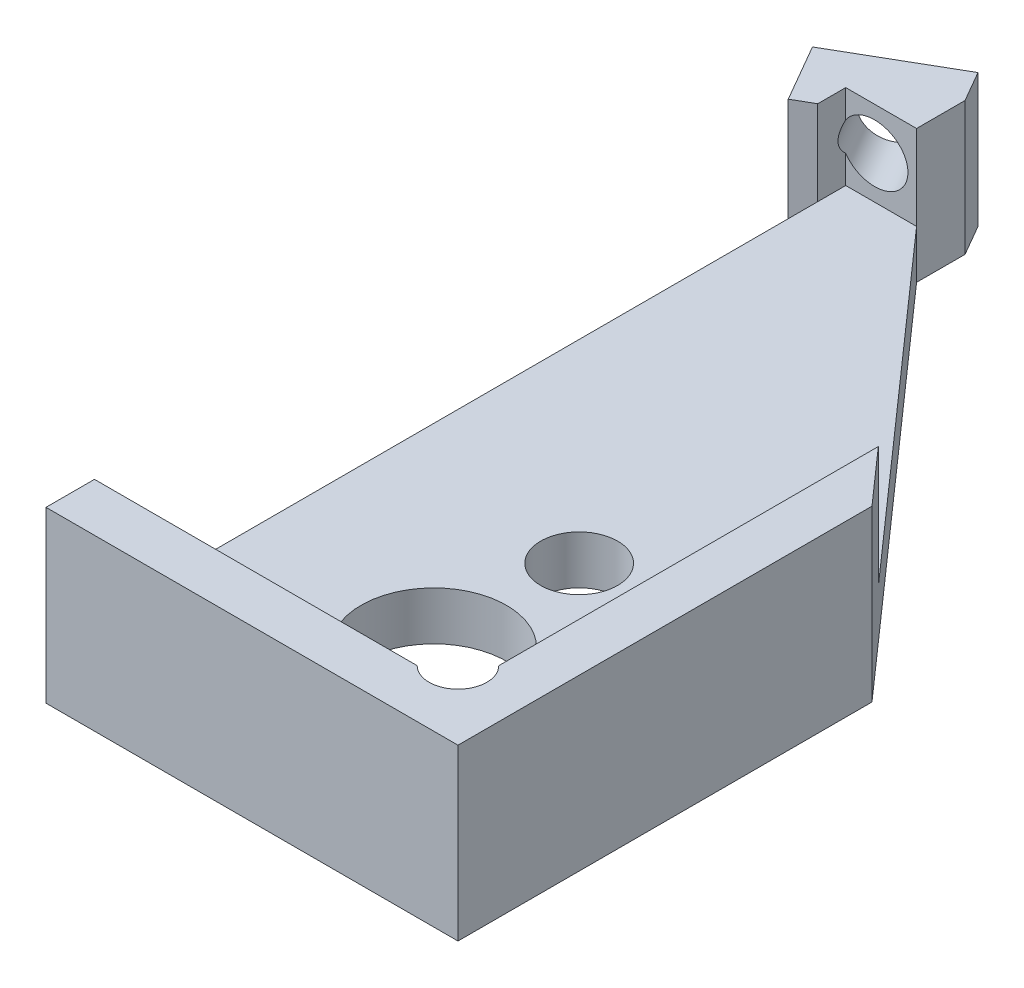
from build123d import *

# Parameters (mm, degrees)
SKETCH1_W                     = 8.5
SKETCH1_H                     = 17.5
BOSS_EXTRUDE1_DEPTH           = 3.5
SKETCH2_W                     = 6.5
SKETCH2_H                     = 15.5
CUT_EXTRUDE1_DEPTH            = 2.5
SKETCH3_R                     = 1.5
GRIN_HOLE_DEPTH               = 2
SKETCH6_R                     = 0.5953125
CORNER_DIVOT_DEPTH            = 2.5
SKETCH7_R                     = 0.79375
MAGNET_HOLES_DEPTH            = 2
BOSS_EXTRUDE2_DEPTH           = 3.5
SKETCH14_W                    = 5.965258944
SKETCH14_H                    = 5.132960456
SET_SCREW_EXTENSION_DEPTH     = 0.75
TAP_DRILL_FOR_0_80_TAP1_D     = 1.19126
TAP_DRILL_FOR_0_80_TAP1_DEPTH = 7.11
TAP_DRILL_FOR_0_80_TAP1_TIP   = 0.357890611
DIAGONAL_CUT_DEPTH            = 5
SKETCH16_W                    = 1
SKETCH16_H                    = 15.5
VERTICAL_CUT_DEPTH            = 3


with BuildPart() as part:
    # Sketch1 → Boss-Extrude1 (new body)
    with BuildSketch(Plane(origin=(0, 0, 0), x_dir=(1, 0, 0), z_dir=(0, 1, 0))):
        Rectangle(SKETCH1_W, SKETCH1_H)
    extrude(amount=BOSS_EXTRUDE1_DEPTH)

    # Sketch2 → Cut-Extrude1 (cut)
    with BuildSketch(Plane(origin=(0, 3.5, 0), x_dir=(1, 0, 0), z_dir=(0, 1, 0))):
        Rectangle(SKETCH2_W, SKETCH2_H)
    extrude(amount=-CUT_EXTRUDE1_DEPTH, mode=Mode.SUBTRACT)

    # Sketch3 → GRIN Hole (cut, through all)
    with BuildSketch(Plane(origin=(0, 1, 0), x_dir=(1, 0, 0), z_dir=(0, 1, 0))):
        with Locations((-0.25, -4.75)):
            Circle(SKETCH3_R)
    extrude(amount=-GRIN_HOLE_DEPTH, mode=Mode.SUBTRACT)

    # Sketch6 → Corner divot (cut)
    with BuildSketch(Plane(origin=(0, 3.5, 0), x_dir=(1, 0, 0), z_dir=(0, 1, 0))):
        with Locations((2.829050494, -7.329050494)):
            Circle(SKETCH6_R)
    extrude(amount=-CORNER_DIVOT_DEPTH, mode=Mode.SUBTRACT)

    # Sketch7 → Magnet Holes (cut, through all)
    with BuildSketch(Plane(origin=(0, 1, 0), x_dir=(1, 0, 0), z_dir=(0, 1, 0))):
        with Locations((-0.25, -1.75)):
            Circle(SKETCH7_R)
        with Locations((-2.125, -6.5)):
            Circle(SKETCH7_R)
        with Locations((1.625, -6.5)):
            Circle(SKETCH7_R)
    extrude(amount=-MAGNET_HOLES_DEPTH, mode=Mode.SUBTRACT)

    # Sketch9 → Boss-Extrude2 (add)
    with BuildSketch(Plane(origin=(0, 3.5, 0), x_dir=(1, 0, 0), z_dir=(0, 1, 0))):
        Polygon((-3.153871189, 9.382850264), (-5.318934698, 8.132850264), (-4.635921996, 6.949837562), (-4.021927306, 7.304327562), (-3.084853178, 7.845347562), (-2.470858487, 8.199837562), align=None)
    extrude(amount=-BOSS_EXTRUDE2_DEPTH)

    # Sketch14 → Set Screw Extension (cut)
    with BuildSketch(Plane(origin=(0, 3.5, 0), x_dir=(1, 0, 0), z_dir=(0, 1, 0))):
        with Locations((-3.25, 7.75)):
            Rectangle(SKETCH14_W, SKETCH14_H)
    extrude(amount=-SET_SCREW_EXTENSION_DEPTH, mode=Mode.SUBTRACT)

    # Tap Drill for #0-80 Tap1
    with Locations(Plane(origin=(-4.851361142, 0, -8.402803983), x_dir=(-0.866025404, 0, 0.5), z_dir=(-0.5, 0, -0.866025404))):
        with Locations((-0.710092562, 1.875)):
            Hole(TAP_DRILL_FOR_0_80_TAP1_D / 2, depth=TAP_DRILL_FOR_0_80_TAP1_DEPTH)
            with Locations((0, 0, -(TAP_DRILL_FOR_0_80_TAP1_DEPTH + TAP_DRILL_FOR_0_80_TAP1_TIP / 2))):  # 118° drill point
                Cone(0, TAP_DRILL_FOR_0_80_TAP1_D / 2, TAP_DRILL_FOR_0_80_TAP1_TIP, mode=Mode.SUBTRACT)

    # Sketch15 → Diagonal Cut (cut)
    with BuildSketch(Plane(origin=(0, 0, 0), x_dir=(1, 0, 0), z_dir=(0, 1, 0))):
        Polygon((-2.788494918, 9.313235547), (-2.788494918, 7.75), (4.25, -0.208562074), (4.25, 9.313235547), align=None)
    extrude(amount=DIAGONAL_CUT_DEPTH, mode=Mode.SUBTRACT)

    # Sketch16 → Vertical Cut (cut)
    with BuildSketch(Plane(origin=(0, 1, 0), x_dir=(1, 0, 0), z_dir=(0, 1, 0))):
        with Locations((-3.75, 0)):
            Rectangle(SKETCH16_W, SKETCH16_H)
    extrude(amount=VERTICAL_CUT_DEPTH, mode=Mode.SUBTRACT)


solid = part.part
